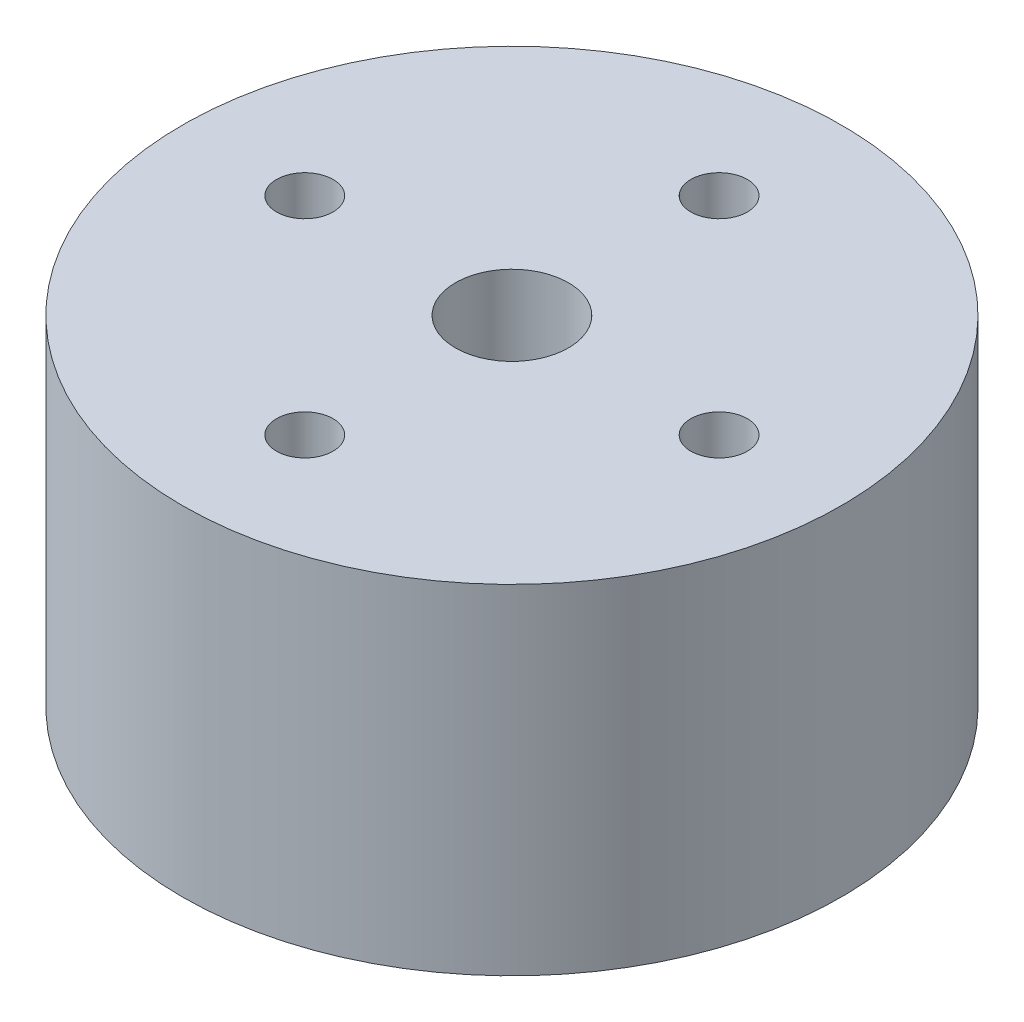
from build123d import *

# Parameters (mm, degrees)
SKETCH1_R           = 17.5
SKETCH1_R_2         = 3
SKETCH1_R_3         = 1.5
BOSS_EXTRUDE1_DEPTH = 18


with BuildPart() as part:
    # Sketch1 → Boss-Extrude1 (new body)
    with BuildSketch(Plane(origin=(0, 0, 0), x_dir=(1, 0, 0), z_dir=(0, 1, 0))):
        Circle(SKETCH1_R)
        Circle(SKETCH1_R_2, mode=Mode.SUBTRACT)
        with Locations((0, 11)):
            Circle(SKETCH1_R_3, mode=Mode.SUBTRACT)
        with Locations((0, -11)):
            Circle(SKETCH1_R_3, mode=Mode.SUBTRACT)
        with Locations((11, 0)):
            Circle(SKETCH1_R_3, mode=Mode.SUBTRACT)
        with Locations((-11, 0)):
            Circle(SKETCH1_R_3, mode=Mode.SUBTRACT)
    extrude(amount=BOSS_EXTRUDE1_DEPTH)


solid = part.part
